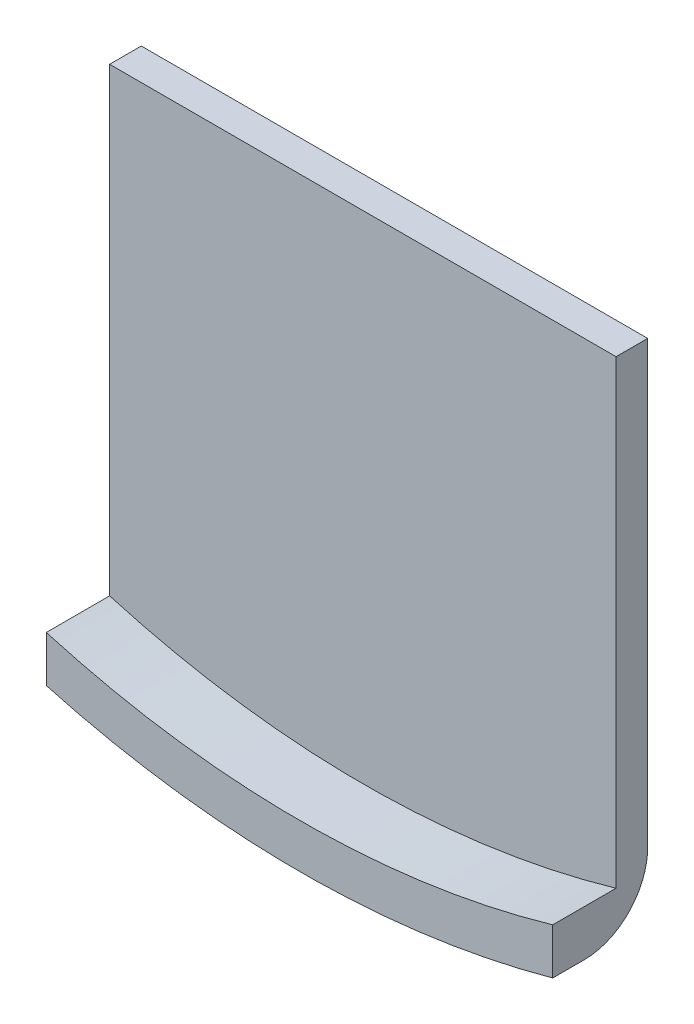
from build123d import *

# Parameters (mm, degrees)
BOSS_EXTRUDE1_DEPTH = 15
CUT_EXTRUDE1_DEPTH  = 10
FILLET1_R           = 10


with BuildPart() as part:
    # Sketch2 → Boss-Extrude1 (new body)
    with BuildSketch(Plane.XY):
        with BuildLine():
            Line((-40, -144.568322948), (-40, -64.568322948))
            Line((-40, -64.568322948), (40, -64.568322948))
            Line((40, -64.568322948), (40, -144.568322948))
            ThreePointArc((40, -144.568322948), (0, -150), (-40, -144.568322948))
        make_face()
    extrude(amount=BOSS_EXTRUDE1_DEPTH)

    # Sketch3 → Cut-Extrude1 (cut)
    with BuildSketch(Plane.XY.offset(15)):
        with BuildLine():
            Line((-40, -137.291660344), (-40, -64.568322948))
            Line((-40, -64.568322948), (40, -64.568322948))
            Line((40, -64.568322948), (40, -137.291660344))
            ThreePointArc((40, -137.291660344), (0, -143), (-40, -137.291660344))
        make_face()
    extrude(amount=-CUT_EXTRUDE1_DEPTH, mode=Mode.SUBTRACT)

    # Fillet1
    fillet1_edges = [part.edges().sort_by_distance(p)[0] for p in [
        (0, -150, 0),
    ]]
    fillet(fillet1_edges, radius=FILLET1_R)


solid = part.part
